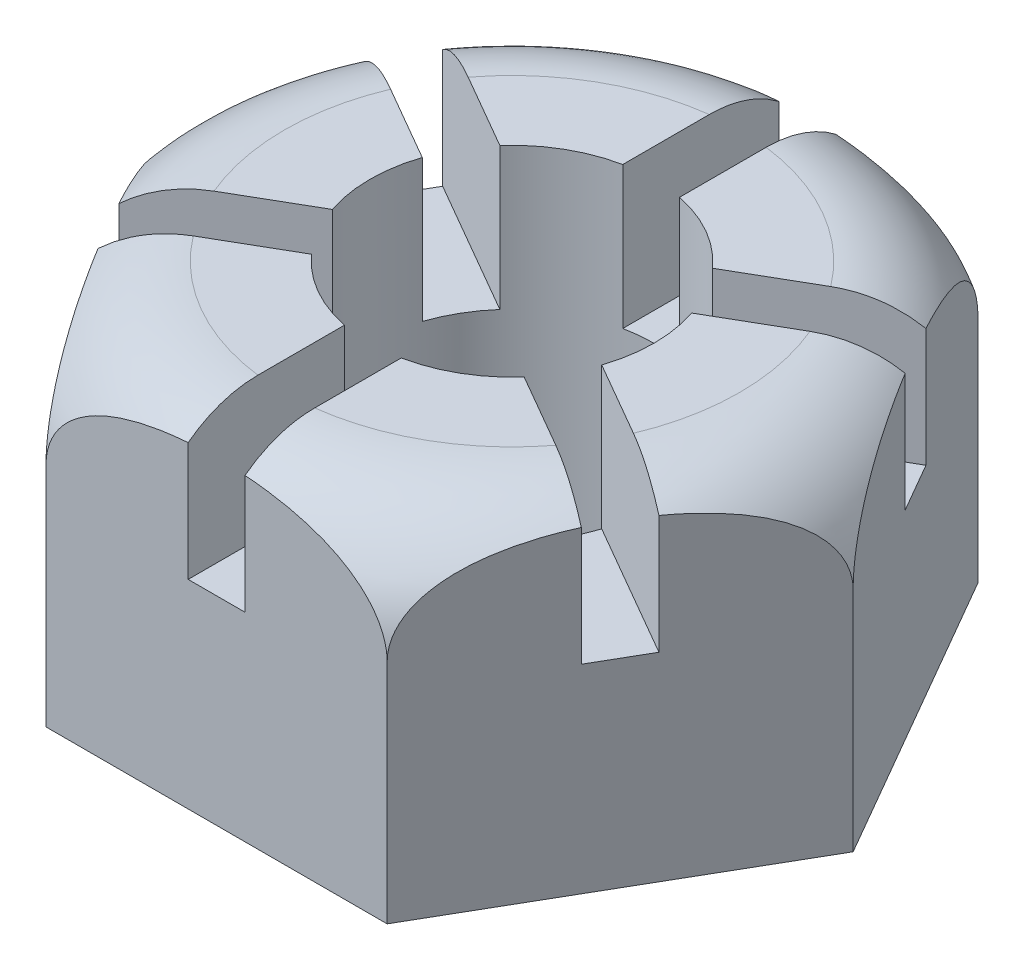
from build123d import *

# Parameters (mm, degrees)
SKETCH1_R           = 25
BOSS_EXTRUDE1_DEPTH = 30
SKETCH5_W           = 10
SKETCH5_H           = 25
CUT_EXTRUDE1_DEPTH  = 67.5
CIRPATTERN1_COUNT   = 6


with BuildPart() as part:
    # Sketch1 → Boss-Extrude1 (new body, symmetric)
    with BuildSketch(Plane(origin=(0, 0, 0), x_dir=(1, 0, 0), z_dir=(0, 1, 0))):
        Polygon((60.044427996, 0), (30.022213998, 52), (-30.022213998, 52), (-60.044427996, 0), (-30.022213998, -52), (30.022213998, -52), align=None)
        Circle(SKETCH1_R, mode=Mode.SUBTRACT)
    extrude(amount=BOSS_EXTRUDE1_DEPTH, both=True)

    # Sketch2 → Cut-Revolve1 (revolve, cut)
    with BuildSketch(Plane.XY):
        with BuildLine():
            Line((-40.044427996, 30), (-34.208162737, 30))
            Line((-34.208162737, 30), (-58.877547107, 44.81594619))
            Line((-58.877547107, 44.81594619), (-76.317667411, 24.773030895))
            Line((-76.317667411, 24.773030895), (-60.044427996, 5.345025428))
            Line((-60.044427996, 5.345025428), (-60.044427996, 10))
            ThreePointArc((-60.044427996, 10), (-54.186563619, 24.142135624), (-40.044427996, 30))
        make_face()
    revolve(axis=Axis((0, 0, 0), (0, 1, 0)), mode=Mode.SUBTRACT)

    # Sketch5 → Cut-Extrude1 (cut, symmetric)
    with BuildSketch(Plane.XY):
        with Locations((0, 17.5)):
            Rectangle(SKETCH5_W, SKETCH5_H)
    cut_extrude1 = extrude(amount=CUT_EXTRUDE1_DEPTH, both=True, mode=Mode.SUBTRACT)

    # CirPattern1: Cut-Extrude1 ×6 about axis
    cirpattern1_axis = Axis((0, 0, 0), (0, 1, 0))
    for i in range(1, CIRPATTERN1_COUNT):
        add(cut_extrude1.rotate(cirpattern1_axis, i * 360 / CIRPATTERN1_COUNT), mode=Mode.SUBTRACT)


solid = part.part
